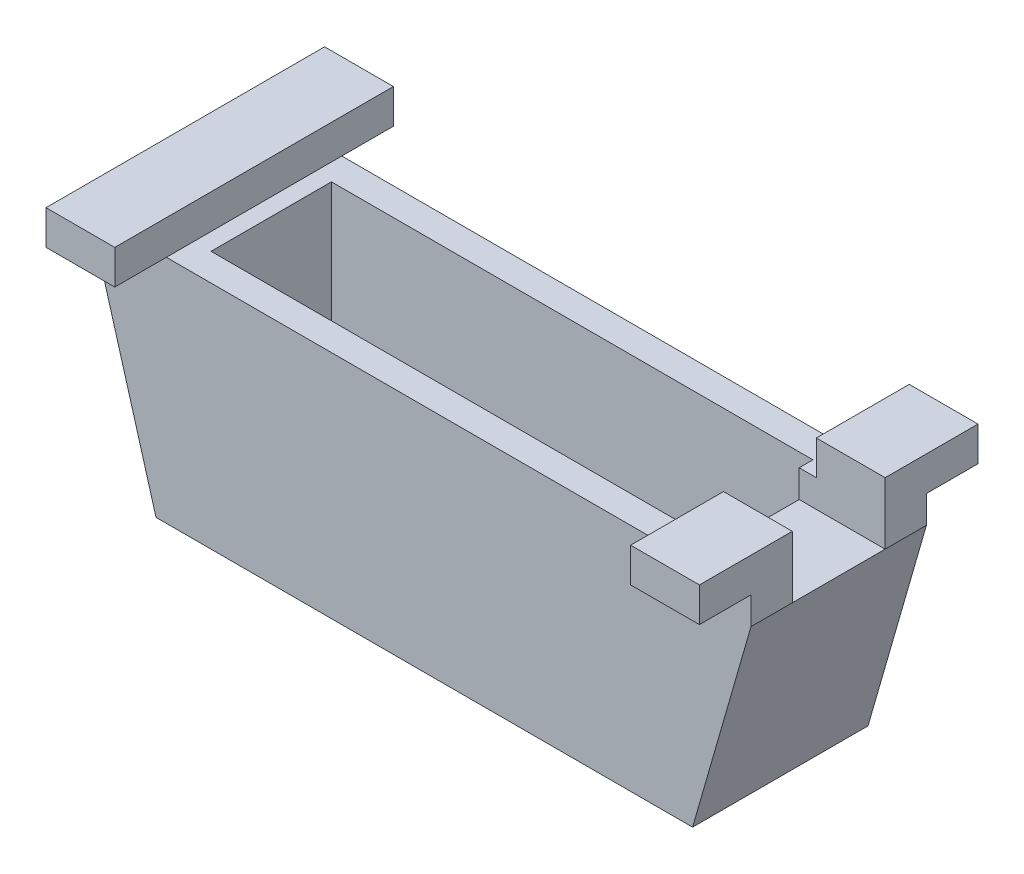
from build123d import *

# Parameters (mm, degrees)
SKETCH1_W                = 88.9
SKETCH1_H                = 22.225
BOSS_EXTRUDE1_DEPTH      = 2.54
SKETCH2_W                = 99.06
SKETCH2_H                = 32.385
SKETCH2_W_2              = 88.9
SKETCH2_H_2              = 22.225
BOSS_EXTRUDE3_DEPTH      = 34.925
BOSS_EXTRUDE3_DEPTH_BACK = 2.54
SKETCH4_W                = 120.635507722
SKETCH4_H                = 32.385
SKETCH4_W_2              = 88.9
SKETCH4_H_2              = 22.225
BOSS_EXTRUDE4_DEPTH      = 5.08
SKETCH5_W                = 12.7
SKETCH5_H                = 51.435
BOSS_EXTRUDE5_DEPTH      = 6.35
BOSS_EXTRUDE6_DEPTH      = 32.385
SKETCH7_W                = 15.867753861
SKETCH7_H                = 17.145
CUT_EXTRUDE1_DEPTH       = 11.43


with BuildPart() as part:
    # Sketch1 → Boss-Extrude1 (new body)
    with BuildSketch(Plane(origin=(0, 0, 0), x_dir=(1, 0, 0), z_dir=(0, 1, 0))):
        Rectangle(SKETCH1_W, SKETCH1_H)
    extrude(amount=BOSS_EXTRUDE1_DEPTH)

    # Sketch2 → Boss-Extrude3 (add, two sides)
    with BuildSketch(Plane(origin=(0, 2.54, 0), x_dir=(1, 0, 0), z_dir=(0, 1, 0))) as boss_extrude3_sk:
        Rectangle(SKETCH2_W, SKETCH2_H)
        Rectangle(SKETCH2_W_2, SKETCH2_H_2, mode=Mode.SUBTRACT)
    extrude(amount=BOSS_EXTRUDE3_DEPTH)
    extrude(boss_extrude3_sk.sketch, amount=-BOSS_EXTRUDE3_DEPTH_BACK)

    # Sketch4 → Boss-Extrude4 (add)
    with BuildSketch(Plane(origin=(0, 37.465, 0), x_dir=(1, 0, 0), z_dir=(0, 1, 0))):
        Rectangle(SKETCH4_W, SKETCH4_H)
        Rectangle(SKETCH4_W_2, SKETCH4_H_2, mode=Mode.SUBTRACT)
    extrude(amount=BOSS_EXTRUDE4_DEPTH)

    # Sketch5 → Boss-Extrude5 (add)
    with BuildSketch(Plane(origin=(0, 42.545, 0), x_dir=(1, 0, 0), z_dir=(0, 1, 0))):
        with Locations((53.967753861, 0)):
            Rectangle(SKETCH5_W, SKETCH5_H)
        with Locations((-53.967753861, 0)):
            Rectangle(SKETCH5_W, SKETCH5_H)
    extrude(amount=BOSS_EXTRUDE5_DEPTH)

    # Sketch6 → Boss-Extrude6 (add)
    with BuildSketch(Plane(origin=(0, 0, -16.1925), x_dir=(-1, 0, 0), z_dir=(0, 0, -1))):
        Polygon((-49.53, 0), (-60.317753861, 37.465), (-49.53, 37.465), align=None)
        Polygon((49.53, 37.465), (60.317753861, 37.465), (49.53, 0), align=None)
    extrude(amount=-BOSS_EXTRUDE6_DEPTH)

    # Sketch7 → Cut-Extrude1 (cut)
    with BuildSketch(Plane(origin=(0, 48.895, 0), x_dir=(1, 0, 0), z_dir=(0, 1, 0))):
        with Locations((52.383876931, 0)):
            Rectangle(SKETCH7_W, SKETCH7_H)
    extrude(amount=-CUT_EXTRUDE1_DEPTH, mode=Mode.SUBTRACT)


solid = part.part
